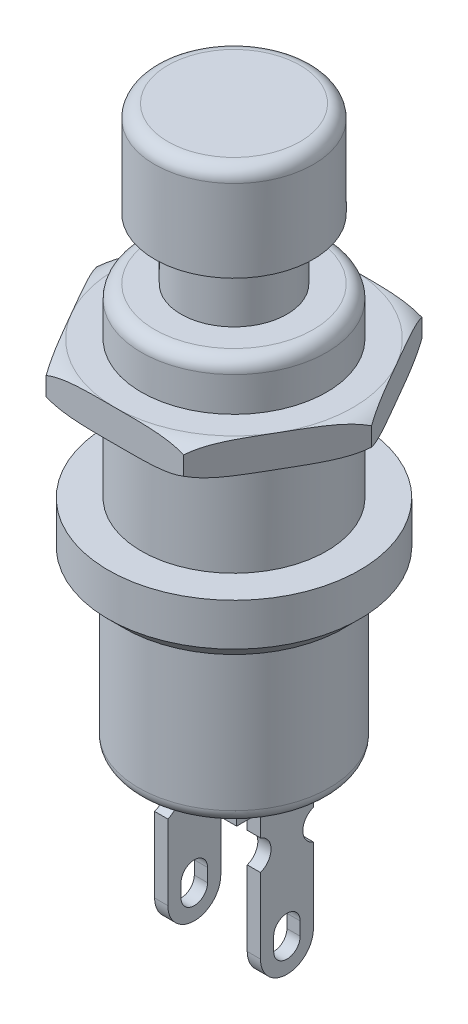
from build123d import *

# Parameters (mm, degrees)
FILLET1_R           = 0.5
BOSS_EXTRUDE1_START = 1.5
BOSS_EXTRUDE1_DEPTH = 0.5
SKETCH3_R           = 0.6
CUT_EXTRUDE1_DEPTH  = 0.5
BOSS_EXTRUDE2_START = 4
SKETCH4_R           = 3.5
BOSS_EXTRUDE2_DEPTH = 1.2


with BuildPart() as part:
    # Sketch1 → Revolve1 (revolve)
    with BuildSketch(Plane.XY):
        Polygon((0, 0), (3.6, 0), (3.6, 6), (4.15, 6), (4.75, 6.6), (4.75, 8.2), (3.5, 8.2), (3.5, 15.2), (2, 15.2), (2, 17.5), (3, 17.5), (3, 21.1), (0, 21.1), align=None)
    revolve(axis=Axis((0, 21.1, 0), (0, -1, 0)))

    # Fillet1
    fillet1_edges = [part.edges().sort_by_distance(p)[0] for p in [
        (-3.5, 15.2, 0),
        (-3.6, 0, 0),
        (-3, 21.1, 0),
    ]]
    fillet(fillet1_edges, radius=FILLET1_R)

    # Sketch2 → Boss-Extrude1 (add)
    with BuildSketch(Plane(origin=(0, 0, 0), x_dir=(0, 0, -1), z_dir=(1, 0, 0)).offset(BOSS_EXTRUDE1_START)):
        with BuildLine():
            Line((-1.9, 0), (-1.9, -0.6))
            Line((-1.9, -0.6), (-1, -0.6))
            Line((-1, -0.6), (-1, -5.4))
            ThreePointArc((-1, -5.4), (0, -6.4), (1, -5.4))
            Line((1, -5.4), (1, -0.6))
            Line((1, -0.6), (1.9, -0.6))
            Line((1.9, -0.6), (1.9, 0))
            Line((1.9, 0), (-1.9, 0))
        make_face()
    boss_extrude1 = extrude(amount=BOSS_EXTRUDE1_DEPTH)

    # Sketch3 → Cut-Extrude1 (cut)
    with BuildSketch(Plane(origin=(2, 0, 0), x_dir=(0, 0, -1), z_dir=(1, 0, 0))):
        with Locations((-1.2, -2)):
            Circle(SKETCH3_R)
        with Locations((1.2, -2)):
            Circle(SKETCH3_R)
        with BuildLine():
            Line((-0.5, -5.4), (-0.5, -4.9))
            ThreePointArc((-0.5, -4.9), (0, -4.4), (0.5, -4.9))
            Line((0.5, -4.9), (0.5, -5.4))
            ThreePointArc((0.5, -5.4), (0, -5.9), (-0.5, -5.4))
        make_face()
    cut_extrude1 = extrude(amount=-CUT_EXTRUDE1_DEPTH, mode=Mode.SUBTRACT)

    # Mirror1: Boss-Extrude1, Cut-Extrude1 across plane
    add(boss_extrude1.mirror(Plane(origin=(0, 0, 0), x_dir=(0, 0, 1), z_dir=(1, 0, 0))))
    add(cut_extrude1.mirror(Plane(origin=(0, 0, 0), x_dir=(0, 0, 1), z_dir=(1, 0, 0))), mode=Mode.SUBTRACT)

    # Sketch4 → Boss-Extrude2 (add)
    with BuildSketch(Plane(origin=(0, 8.2, 0), x_dir=(1, 0, 0), z_dir=(0, 1, 0)).offset(BOSS_EXTRUDE2_START)):
        Polygon((5.196152423, 0), (2.598076211, 4.5), (-2.598076211, 4.5), (-5.196152423, 0), (-2.598076211, -4.5), (2.598076211, -4.5), align=None)
        Circle(SKETCH4_R, mode=Mode.SUBTRACT)
    extrude(amount=BOSS_EXTRUDE2_DEPTH)

    # Sketch5 → Cut-Revolve1 (revolve, cut)
    with BuildSketch(Plane.XY):
        with BuildLine():
            Line((-5.196152423, 13.4), (-4.5, 13.4))
            ThreePointArc((-4.5, 13.4), (-4.869840572, 13.33560525), (-5.196152423, 13.15))
            Line((-5.196152423, 13.15), (-5.196152423, 13.4))
        make_face()
        with BuildLine():
            Line((-4.5, 12.2), (-5.196152423, 12.2))
            Line((-5.196152423, 12.2), (-5.196152423, 12.45))
            ThreePointArc((-5.196152423, 12.45), (-4.869840572, 12.26439475), (-4.5, 12.2))
        make_face()
    revolve(axis=Axis((0, 13.4, 0), (0, -1, 0)), mode=Mode.SUBTRACT)


solid = part.part
